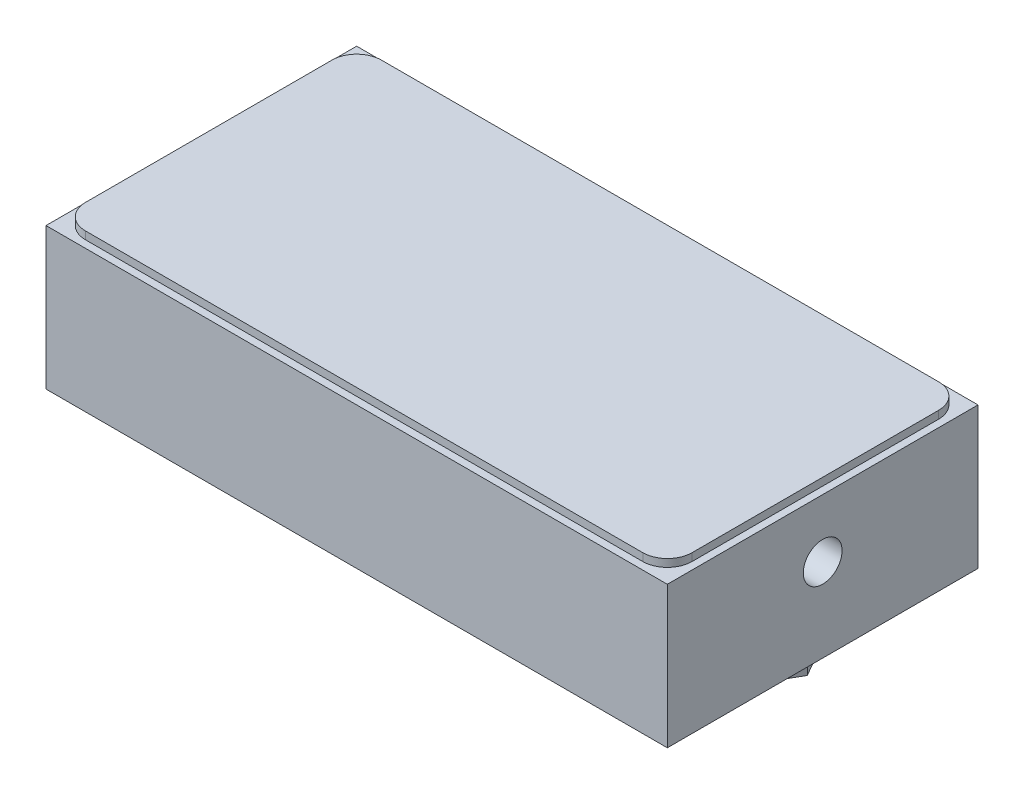
from build123d import *

# Parameters (mm, degrees)
SKETCH1_W                          = 80
SKETCH1_H                          = 40
EXTRUDE1_DEPTH                     = 18.9992
F_1_8_0_125_DIAMETER_HOLE1_D       = 3.175
F_1_8_0_125_DIAMETER_HOLE1_DEPTH   = 6.35
F_1_8_0_125_DIAMETER_HOLE1_TIP     = 0.953866233
M3X0_5_TAPPED_HOLE1_D              = 2.5
M3X0_5_TAPPED_HOLE1_DEPTH          = 8.849995
M3X0_5_TAPPED_HOLE1_CBORE_D        = 3
M3X0_5_TAPPED_HOLE1_CBORE_DEPTH    = 6.35
M3X0_5_TAPPED_HOLE1_TIP            = 0.751075774
M5X0_8_TAPPED_HOLE1_D              = 4.2
M5X0_8_TAPPED_HOLE1_CBORE_D        = 5
M5X0_8_TAPPED_HOLE1_CBORE_DEPTH    = 5.08
F_3_16_0_1875_DIAMETER_HOLE1_D     = 4.7625
F_3_16_0_1875_DIAMETER_HOLE1_DEPTH = 6.2484
CUT_REVOLVE1_ANGLE                 = 180
M5X0_8_TAPPED_HOLE2_D              = 4.2
M5X0_8_TAPPED_HOLE2_DEPTH          = 6.6
M5X0_8_TAPPED_HOLE2_CBORE_D        = 5
M5X0_8_TAPPED_HOLE2_CBORE_DEPTH    = 5.08
CIRPATTERN1_COUNT                  = 3
CHAMFER1_SIZE                      = 0.762
EXTRUDE2_DEPTH                     = 0.9906
EXTRUDE3_DEPTH                     = 2.159


with BuildPart() as part:
    # Sketch1 → Extrude1 (new body)
    with BuildSketch(Plane(origin=(0, 0, 0), x_dir=(1, 0, 0), z_dir=(0, 1, 0))):
        Rectangle(SKETCH1_W, SKETCH1_H)
    extrude(amount=EXTRUDE1_DEPTH)

    # 1_8 _0.125_ Diameter Hole1
    with Locations(Plane.XZ):
        with Locations((-20, 0)):
            Hole(F_1_8_0_125_DIAMETER_HOLE1_D / 2, depth=F_1_8_0_125_DIAMETER_HOLE1_DEPTH)
            with Locations((0, 0, -(F_1_8_0_125_DIAMETER_HOLE1_DEPTH + F_1_8_0_125_DIAMETER_HOLE1_TIP / 2))):  # 118° drill point
                Cone(0, F_1_8_0_125_DIAMETER_HOLE1_D / 2, F_1_8_0_125_DIAMETER_HOLE1_TIP, mode=Mode.SUBTRACT)

    # M3x0.5 Tapped Hole1
    with Locations(Plane.XZ):
        with Locations((20, 0)):
            CounterBoreHole(M3X0_5_TAPPED_HOLE1_D / 2, M3X0_5_TAPPED_HOLE1_CBORE_D / 2, M3X0_5_TAPPED_HOLE1_CBORE_DEPTH, depth=M3X0_5_TAPPED_HOLE1_DEPTH)
            with Locations((0, 0, -(M3X0_5_TAPPED_HOLE1_DEPTH + M3X0_5_TAPPED_HOLE1_TIP / 2))):  # 118° drill point
                Cone(0, M3X0_5_TAPPED_HOLE1_D / 2, M3X0_5_TAPPED_HOLE1_TIP, mode=Mode.SUBTRACT)

    # M5x0.8 Tapped Hole1 (through all)
    with Locations(Plane.XZ):
        with Locations((33.4, 0)):
            CounterBoreHole(M5X0_8_TAPPED_HOLE1_D / 2, M5X0_8_TAPPED_HOLE1_CBORE_D / 2, M5X0_8_TAPPED_HOLE1_CBORE_DEPTH)

    # 3_16 _0.1875_ Diameter Hole1
    with Locations(Plane.XZ):
        with Locations((0, 0)):
            Hole(F_3_16_0_1875_DIAMETER_HOLE1_D / 2, depth=F_3_16_0_1875_DIAMETER_HOLE1_DEPTH)

    # Sketch12 → Cut-Revolve1 (revolve, cut)
    with BuildSketch(Plane.XZ.offset(0.508)):
        with BuildLine():
            Line((0, 6.5024), (0, -6.5024))
            ThreePointArc((0, -6.5024), (6.5024, 0), (0, 6.5024))
        make_face()
    revolve(axis=Axis((0, -0.508, 6.5024), (0, 0, 1)), revolution_arc=CUT_REVOLVE1_ANGLE, mode=Mode.SUBTRACT)

    # M5x0.8 Tapped Hole2
    with Locations(Plane(origin=(40, 0, 0), x_dir=(0, 0, -1), z_dir=(1, 0, 0))):
        with Locations((0, 11.5062)):
            CounterBoreHole(M5X0_8_TAPPED_HOLE2_D / 2, M5X0_8_TAPPED_HOLE2_CBORE_D / 2, M5X0_8_TAPPED_HOLE2_CBORE_DEPTH, depth=M5X0_8_TAPPED_HOLE2_DEPTH)

    # Sketch15 → M3x0.5 Tapped Hole2 (revolve, cut)
    with BuildSketch(Plane(origin=(0, 0, -10.795), x_dir=(0, 0, -1), z_dir=(1, 0, 0))):
        Polygon((0, 0), (0, 9.601070774), (1.25, 8.849995), (1.25, 6.35), (1.5, 6.35), (1.5, 0), align=None)
    m3x0_5_tapped_hole2 = revolve(axis=Axis((0, -6.35, -10.795), (0, 1, 0)), mode=Mode.SUBTRACT)

    # CirPattern1: M3x0.5 Tapped Hole2 ×3 about axis
    cirpattern1_axis = Axis((0, 0, 0), (0, 1, 0))
    for i in range(1, CIRPATTERN1_COUNT):
        add(m3x0_5_tapped_hole2.rotate(cirpattern1_axis, i * 360 / CIRPATTERN1_COUNT), mode=Mode.SUBTRACT)

    # Chamfer1
    chamfer1_edges = [part.edges().sort_by_distance(p)[0] for p in [
        (0, 0, -20),
        (40, 0, 0),
        (0, 0, 20),
        (-40, 0, 0),
    ]]
    chamfer(chamfer1_edges, length=CHAMFER1_SIZE)

    # Sketch2 → Extrude2 (add)
    with BuildSketch(Plane(origin=(0, 18.9992, 0), x_dir=(-1, 0, 0), z_dir=(0, 1, 0))):
        with BuildLine():
            Line((35.8725, 19.0475), (-35.8825, 19.0475))
            ThreePointArc((-35.8825, 19.0475), (-38.12756403, 18.11756403), (-39.0575, 15.8725))
            Line((-39.0575, 15.8725), (-39.0575, -15.8775))
            ThreePointArc((-39.0575, -15.8775), (-38.12756403, -18.12256403), (-35.8825, -19.0525))
            Line((-35.8825, -19.0525), (35.8725, -19.0525))
            ThreePointArc((35.8725, -19.0525), (38.11756403, -18.12256403), (39.0475, -15.8775))
            Line((39.0475, -15.8775), (39.0475, 15.8725))
            ThreePointArc((39.0475, 15.8725), (38.11756403, 18.11756403), (35.8725, 19.0475))
        make_face()
    extrude(amount=EXTRUDE2_DEPTH)

    # Sketch17 → Extrude3 (add)
    with BuildSketch(Plane.XZ):
        Polygon((31.0886, -4.003386697), (35.7114, -4.003386697), (38.022930833, 0), (35.7114, 4.003386697), (31.0886, 4.003386697), (28.777069167, 0), align=None)
    extrude(amount=EXTRUDE3_DEPTH)


solid = part.part
